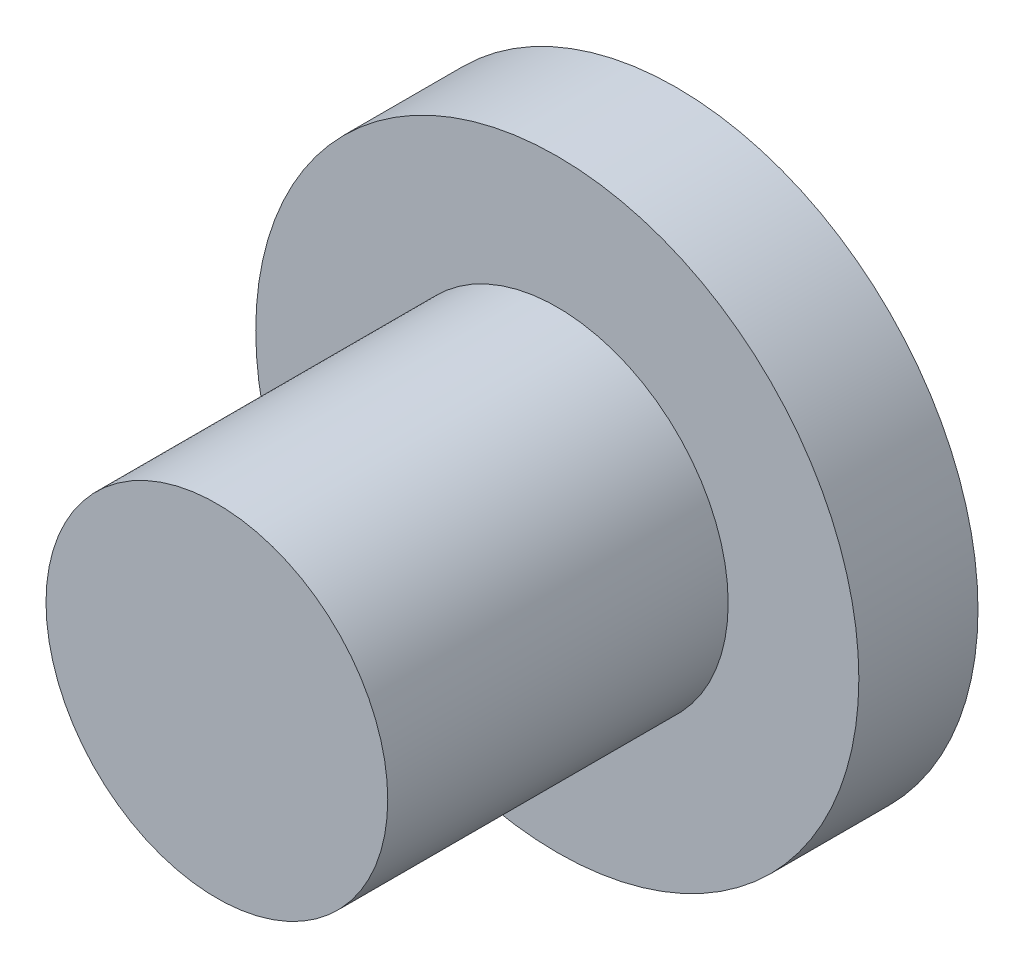
from build123d import *

# Parameters (mm, degrees)
SKETCH1_R           = 4.5
BOSS_EXTRUDE2_DEPTH = 1.778
SKETCH2_R           = 2.55
BOSS_EXTRUDE4_DEPTH = 5.08


with BuildPart() as part:
    # Sketch1 → Boss-Extrude2 (new body)
    with BuildSketch(Plane.XY):
        with Locations((-10.060269198, 7.746407282)):
            Circle(SKETCH1_R)
    extrude(amount=BOSS_EXTRUDE2_DEPTH)

    # Sketch2 → Boss-Extrude4 (add)
    with BuildSketch(Plane.XY.offset(1.778)):
        with Locations((-10.060269198, 7.746407282)):
            Circle(SKETCH2_R)
    extrude(amount=BOSS_EXTRUDE4_DEPTH)


solid = part.part
